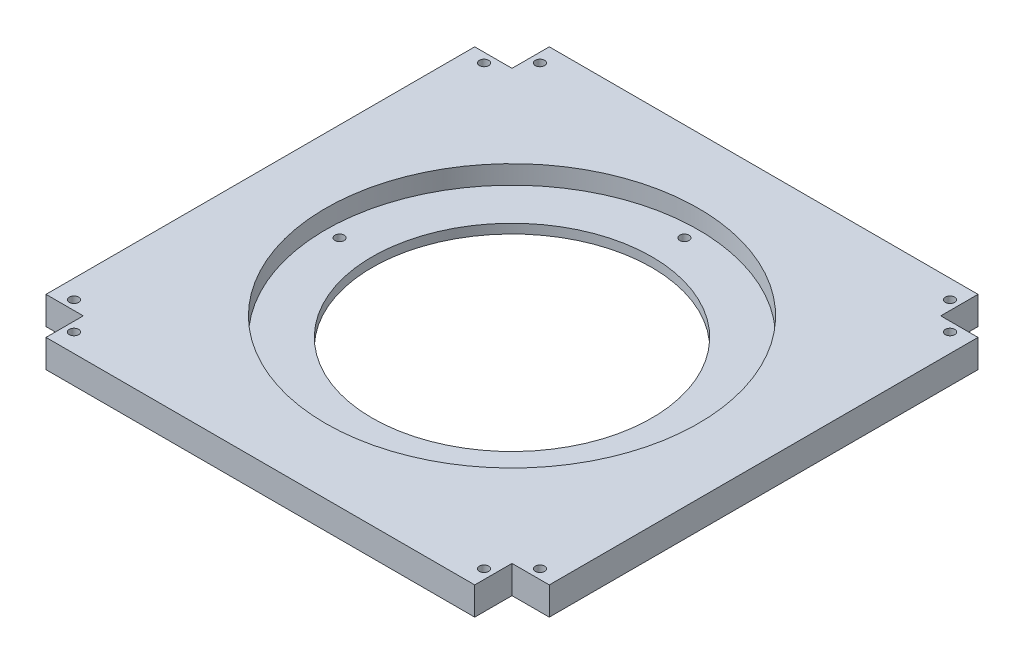
from build123d import *

# Parameters (mm, degrees)
SKETCH1_W           = 270
SKETCH1_H           = 270
BOSS_EXTRUDE1_DEPTH = 15
SKETCH8_W           = 20
SKETCH8_H           = 20
CUT_EXTRUDE1_DEPTH  = 16
SKETCH9_R           = 2.5
CUT_EXTRUDE2_DEPTH  = 16
SKETCH10_R          = 100
CUT_EXTRUDE3_DEPTH  = 10
SKETCH12_R          = 75
SKETCH12_R_2        = 2.5
CUT_EXTRUDE4_DEPTH  = 6


with BuildPart() as part:
    # Sketch1 → Boss-Extrude1 (new body)
    with BuildSketch(Plane(origin=(0, 0, 0), x_dir=(1, 0, 0), z_dir=(0, 1, 0))):
        with Locations((135, 135)):
            Rectangle(SKETCH1_W, SKETCH1_H)
    extrude(amount=BOSS_EXTRUDE1_DEPTH)

    # Sketch8 → Cut-Extrude1 (cut, through all)
    with BuildSketch(Plane(origin=(0, 15, 0), x_dir=(1, 0, 0), z_dir=(0, 1, 0))):
        with Locations((10, 260)):
            Rectangle(SKETCH8_W, SKETCH8_H)
        with Locations((260, 260)):
            Rectangle(SKETCH8_W, SKETCH8_H)
        with Locations((260, 10)):
            Rectangle(SKETCH8_W, SKETCH8_H)
        with Locations((10, 10)):
            Rectangle(SKETCH8_W, SKETCH8_H)
    extrude(amount=-CUT_EXTRUDE1_DEPTH, mode=Mode.SUBTRACT)

    # Sketch9 → Cut-Extrude2 (cut, through all)
    with BuildSketch(Plane(origin=(0, 15, 0), x_dir=(1, 0, 0), z_dir=(0, 1, 0))):
        with Locations((10, 245)):
            Circle(SKETCH9_R)
        with Locations((10, 25)):
            Circle(SKETCH9_R)
        with Locations((25, 10)):
            Circle(SKETCH9_R)
        with Locations((245, 10)):
            Circle(SKETCH9_R)
        with Locations((260, 25)):
            Circle(SKETCH9_R)
        with Locations((260, 245)):
            Circle(SKETCH9_R)
        with Locations((245, 260)):
            Circle(SKETCH9_R)
        with Locations((25, 260)):
            Circle(SKETCH9_R)
    extrude(amount=-CUT_EXTRUDE2_DEPTH, mode=Mode.SUBTRACT)

    # Sketch10 → Cut-Extrude3 (cut)
    with BuildSketch(Plane(origin=(0, 15, 0), x_dir=(1, 0, 0), z_dir=(0, 1, 0))):
        with Locations((135, 135)):
            Circle(SKETCH10_R)
    extrude(amount=-CUT_EXTRUDE3_DEPTH, mode=Mode.SUBTRACT)

    # Sketch12 → Cut-Extrude4 (cut, through all)
    with BuildSketch(Plane(origin=(0, 5, 0), x_dir=(1, 0, 0), z_dir=(0, 1, 0))):
        with Locations((135, 135)):
            Circle(SKETCH12_R)
        with Locations((135, 227.5)):
            Circle(SKETCH12_R_2)
        with Locations((227.5, 135)):
            Circle(SKETCH12_R_2)
        with Locations((135, 42.5)):
            Circle(SKETCH12_R_2)
        with Locations((42.5, 135)):
            Circle(SKETCH12_R_2)
    extrude(amount=-CUT_EXTRUDE4_DEPTH, mode=Mode.SUBTRACT)


solid = part.part
